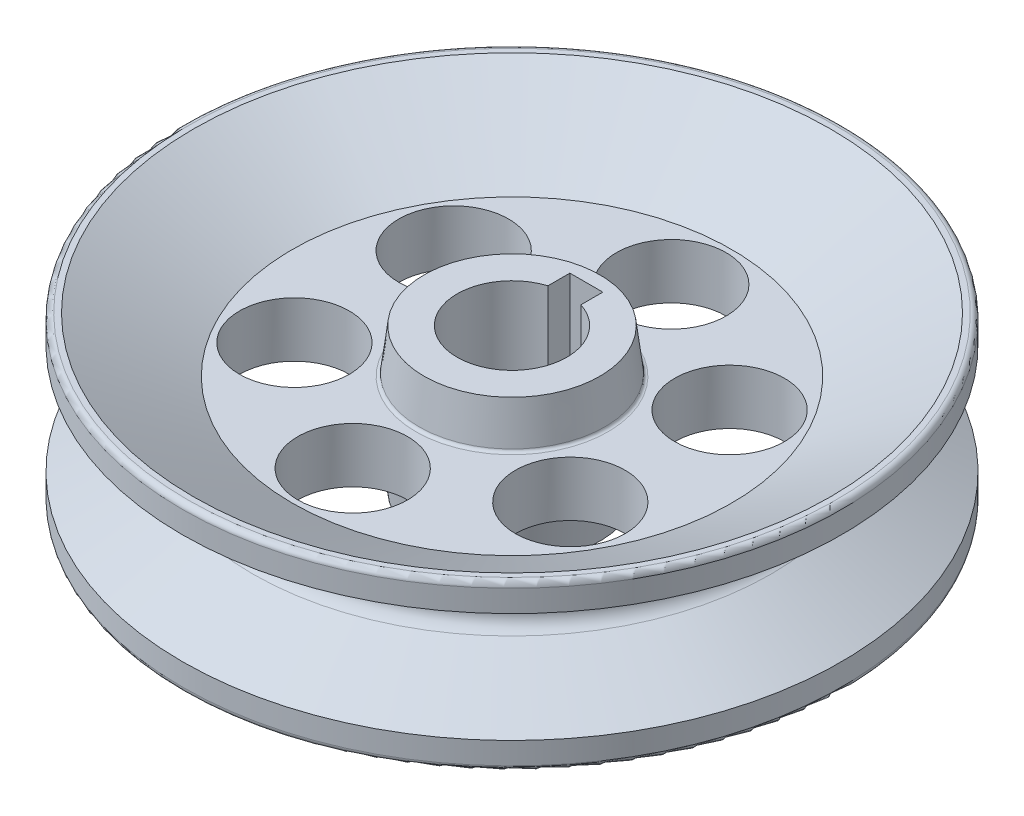
from build123d import *

# Parameters (mm, degrees)
SKETCH1_R           = 1524
BOSS_EXTRUDE1_DEPTH = 381
CUT_EXTRUDE1_DEPTH  = 763
SKETCH4_R           = 254
CUT_EXTRUDE2_DEPTH  = 763
CIRPATTERN1_COUNT   = 6
FILLET3_R           = 25.4


with BuildPart() as part:
    # Sketch1 → Boss-Extrude1 (new body, symmetric)
    with BuildSketch(Plane(origin=(0, 0, 0), x_dir=(1, 0, 0), z_dir=(0, 1, 0))):
        Circle(SKETCH1_R)
    extrude(amount=BOSS_EXTRUDE1_DEPTH, both=True)

    # Sketch2 → Cut-Revolve1 (revolve, cut)
    with BuildSketch(Plane(origin=(0, 0, 0), x_dir=(0, 0, -1), z_dir=(1, 0, 0))):
        with BuildLine():
            Line((1524, -254), (1524, 254))
            Line((1524, 254), (1198.359094878, 65.991135768))
            ThreePointArc((1198.359094878, 65.991135768), (1160.259094878, 0), (1198.359094878, -65.991135768))
            Line((1198.359094878, -65.991135768), (1524, -254))
        make_face()
    revolve(axis=Axis((0, 381, 0), (0, -1, 0)), mode=Mode.SUBTRACT)

    # Sketch3 → Cut-Extrude1 (cut, through all)
    with BuildSketch(Plane(origin=(0, 381, 0), x_dir=(1, 0, 0), z_dir=(0, 1, 0))):
        with BuildLine():
            Line((-76.2, 242.30055716), (-76.2, 343.90055716))
            Line((-76.2, 343.90055716), (76.2, 343.90055716))
            Line((76.2, 343.90055716), (76.2, 242.30055716))
            ThreePointArc((76.2, 242.30055716), (0, -254), (-76.2, 242.30055716))
        make_face()
    extrude(amount=-CUT_EXTRUDE1_DEPTH, mode=Mode.SUBTRACT)

    # Sketch4 → Cut-Extrude2 (cut, through all)
    with BuildSketch(Plane(origin=(0, 381, 0), x_dir=(1, 0, 0), z_dir=(0, 1, 0))):
        with Locations((0, 736.6)):
            Circle(SKETCH4_R)
    cut_extrude2 = extrude(amount=-CUT_EXTRUDE2_DEPTH, mode=Mode.SUBTRACT)

    # CirPattern1: Cut-Extrude2 ×6 about axis
    cirpattern1_axis = Axis((0, 0, 0), (0, 1, 0))
    for i in range(1, CIRPATTERN1_COUNT):
        add(cut_extrude2.rotate(cirpattern1_axis, i * 360 / CIRPATTERN1_COUNT), mode=Mode.SUBTRACT)

    # Sketch7 → Cut-Revolve3 (revolve, cut)
    with BuildSketch(Plane(origin=(0, 0, 0), x_dir=(0, 0, -1), z_dir=(1, 0, 0))):
        with BuildLine():
            Line((406.4, 330.2), (430.137519746, 139.684026625))
            ThreePointArc((430.137519746, 139.684026625), (434.919220146, 130.62494696), (444.5, 127))
            Line((444.5, 127), (1016, 127))
            Line((1016, 127), (1473.2, 381))
            Line((1473.2, 381), (0, 381))
            Line((0, 381), (0, 330.2))
            Line((0, 330.2), (406.4, 330.2))
        make_face()
        with BuildLine():
            Line((0, -330.2), (0, -381))
            Line((0, -381), (1473.2, -381))
            Line((1473.2, -381), (1016, -127))
            Line((1016, -127), (444.5, -127))
            ThreePointArc((444.5, -127), (434.919220146, -130.62494696), (430.137519746, -139.684026625))
            Line((430.137519746, -139.684026625), (406.4, -330.2))
            Line((406.4, -330.2), (0, -330.2))
        make_face()
    revolve(axis=Axis((0, 254, 0), (0, 1, 0)), mode=Mode.SUBTRACT)

    # Fillet3
    fillet3_edges = [part.edges().sort_by_distance(p)[0] for p in [
        (-1524, -381, 0),
        (-1524, 381, 0),
    ]]
    fillet(fillet3_edges, radius=FILLET3_R)


solid = part.part
